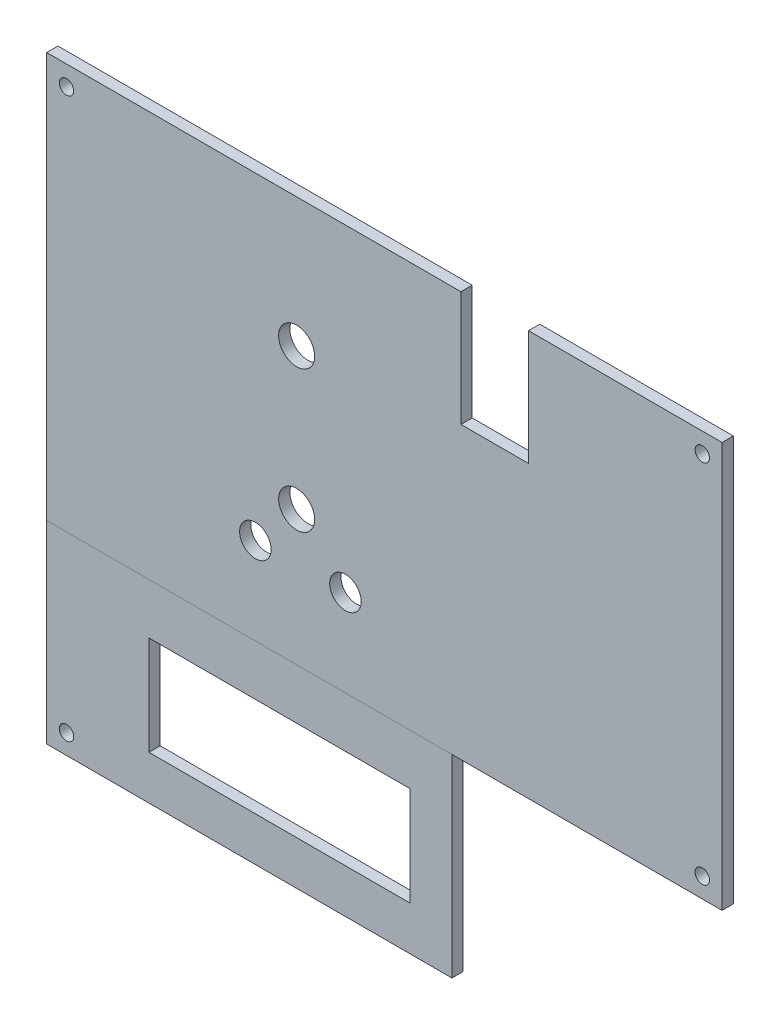
from build123d import *

# Parameters (mm, degrees)
SKETCH2_R           = 4.445
SKETCH2_R_2         = 5.08
BOSS_EXTRUDE1_DEPTH = 3.175
SKETCH3_W           = 114.3
SKETCH3_H           = 54.61
BOSS_EXTRUDE2_DEPTH = 3.175
SKETCH4_W           = 73.66
SKETCH4_H           = 27.94
CUT_EXTRUDE1_DEPTH  = 3.175
SKETCH6_R           = 2.032
CUT_EXTRUDE2_DEPTH  = 4.175


with BuildPart() as part:
    # Sketch2 → Boss-Extrude1 (new body)
    with BuildSketch(Plane.XY):
        Polygon((106.654477728, 105.0036), (-10.185522272, 105.0036), (-10.185522272, -9.2964), (180.314477728, -9.2964), (180.314477728, 105.0036), (125.704477728, 105.0036), (125.704477728, 72.572919742), (106.654477728, 72.572919742), align=None)
        with Locations((48.6791, 15.24)):
            Circle(SKETCH2_R, mode=Mode.SUBTRACT)
        with Locations((74.0791, 15.24)):
            Circle(SKETCH2_R, mode=Mode.SUBTRACT)
        with Locations((60.325, 28.702)):
            Circle(SKETCH2_R_2, mode=Mode.SUBTRACT)
        with Locations((60.325, 68.58)):
            Circle(SKETCH2_R_2, mode=Mode.SUBTRACT)
    extrude(amount=BOSS_EXTRUDE1_DEPTH)


with BuildPart() as body_2:
    # Sketch3 → Boss-Extrude2 (new body)
    with BuildSketch(Plane.XY.offset(3.175)):
        with Locations((46.964477728, -36.6014)):
            Rectangle(SKETCH3_W, SKETCH3_H)
    extrude(amount=-BOSS_EXTRUDE2_DEPTH)

    # Sketch4 → Cut-Extrude1 (cut)
    with BuildSketch(Plane.XY.offset(3.175)):
        with Locations((55.471174167, -37.539907166)):
            Rectangle(SKETCH4_W, SKETCH4_H)
    extrude(amount=-CUT_EXTRUDE1_DEPTH, mode=Mode.SUBTRACT)


with BuildPart() as cut_extrude2_tool:
    # Sketch6 → Cut-Extrude2 (new body, through all)
    with BuildSketch(Plane.XY.offset(3.175)):
        with Locations((-4.597522272, 99.4156)):
            Circle(SKETCH6_R)
        with Locations((174.726477728, 99.4156)):
            Circle(SKETCH6_R)
        with Locations((174.726477728, -3.7084)):
            Circle(SKETCH6_R)
        with Locations((-4.597522272, -58.3184)):
            Circle(SKETCH6_R)
    extrude(amount=-CUT_EXTRUDE2_DEPTH)


with BuildPart() as part_1:
    add(part.part)

    # Cut-Extrude2: cut by cut_extrude2_tool
    add(cut_extrude2_tool.part, mode=Mode.SUBTRACT)


with BuildPart() as body_2_1:
    add(body_2.part)

    # Cut-Extrude2: cut by cut_extrude2_tool
    add(cut_extrude2_tool.part, mode=Mode.SUBTRACT)


solid = Compound([part_1.part, body_2_1.part])
